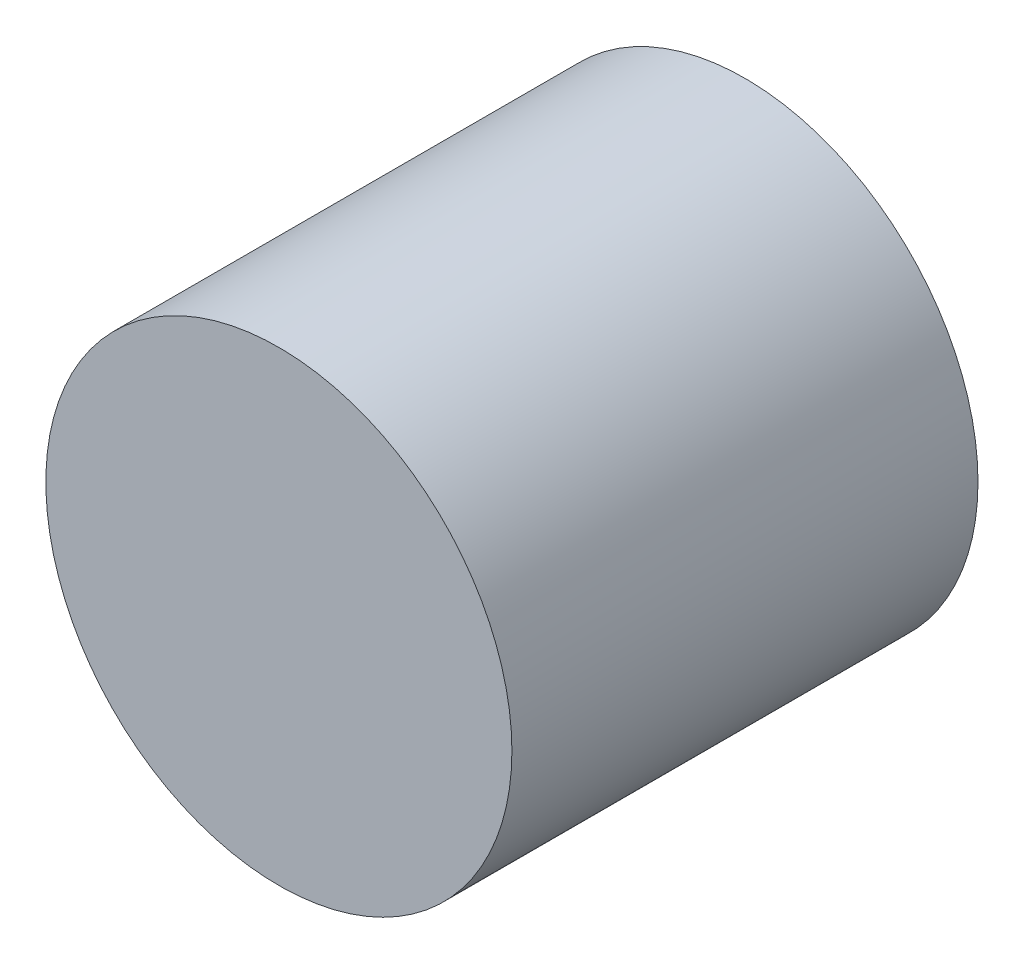
from build123d import *

# Parameters (mm, degrees)
SKETCH1_R           = 25.4
BOSS_EXTRUDE1_DEPTH = 50.8


with BuildPart() as part:
    # Sketch1 → Boss-Extrude1 (new body)
    with BuildSketch(Plane.XY):
        with Locations((-25.538725984, 9.417405207)):
            Circle(SKETCH1_R)
    extrude(amount=BOSS_EXTRUDE1_DEPTH)


solid = part.part
